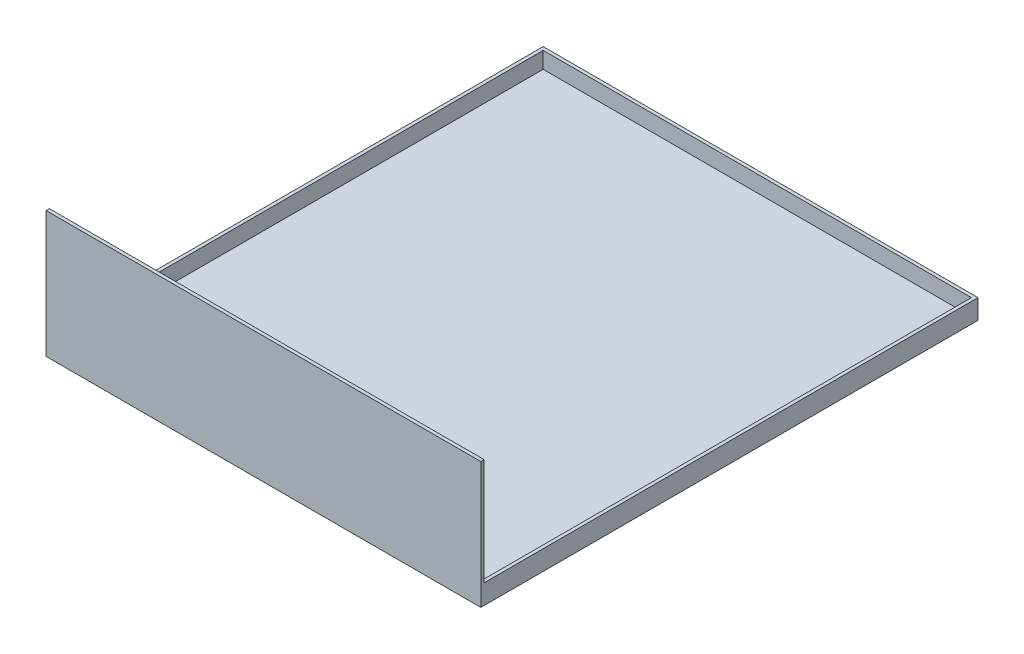
from build123d import *

# Parameters (mm, degrees)
SKETCH1_W           = 265
SKETCH1_H           = 62
BOSS_EXTRUDE1_DEPTH = 303
SHELL1_T            = -2
SKETCH2_W           = 265
SKETCH2_H           = 301
CUT_EXTRUDE1_DEPTH  = 50
SKETCH3_W           = 265
SKETCH3_H           = 2
BOSS_EXTRUDE2_DEPTH = 15


with BuildPart() as part:
    # Sketch1 → Boss-Extrude1 (new body)
    with BuildSketch(Plane.XY):
        Rectangle(SKETCH1_W, SKETCH1_H)
    extrude(amount=BOSS_EXTRUDE1_DEPTH)

    # Shell1
    shell1_openings = [part.faces().sort_by_distance(p)[0] for p in [
        (0, 31, 151.5),
    ]]
    offset(amount=SHELL1_T, openings=shell1_openings, kind=Kind.INTERSECTION)

    # Sketch2 → Cut-Extrude1 (cut)
    with BuildSketch(Plane(origin=(0, 31, 0), x_dir=(1, 0, 0), z_dir=(0, 1, 0))):
        with Locations((0, -150.5)):
            Rectangle(SKETCH2_W, SKETCH2_H)
    extrude(amount=-CUT_EXTRUDE1_DEPTH, mode=Mode.SUBTRACT)

    # Sketch3 → Boss-Extrude2 (add)
    with BuildSketch(Plane(origin=(0, 31, 0), x_dir=(1, 0, 0), z_dir=(0, 1, 0))):
        with Locations((0, -302)):
            Rectangle(SKETCH3_W, SKETCH3_H)
    extrude(amount=BOSS_EXTRUDE2_DEPTH)


solid = part.part
